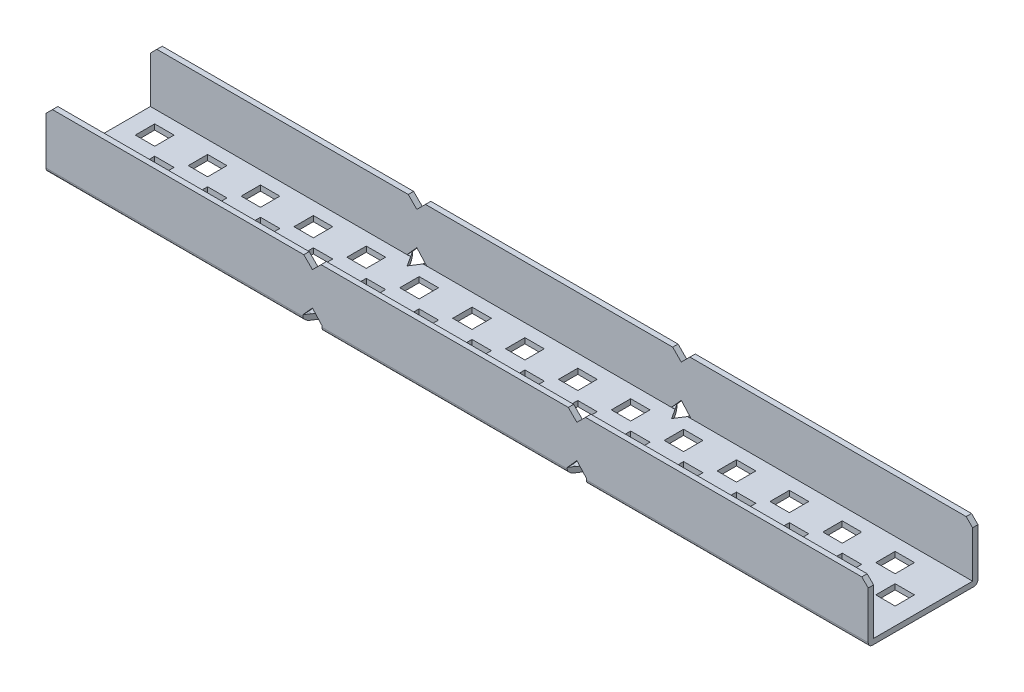
from build123d import *

# Parameters (mm, degrees)
SKETCH1_W           = 191
SKETCH1_H           = 25.5
BOSS_EXTRUDE1_DEPTH = 1.25
SKETCH2_W           = 191
SKETCH2_H           = 1.25
BOSS_EXTRUDE2_DEPTH = 12.25
SKETCH3_W           = 4.5
SKETCH3_H           = 4.5
CUT_EXTRUDE1_DEPTH  = 12.25
CUT_EXTRUDE2_DEPTH  = 1.3
CUT_EXTRUDE4_DEPTH  = 48.3
CUT_EXTRUDE5_DEPTH  = 48.3
FILLET1_R           = 1


with BuildPart() as part:
    # Sketch1 → Boss-Extrude1 (new body)
    with BuildSketch(Plane(origin=(0, 0, 0), x_dir=(1, 0, 0), z_dir=(0, 1, 0))):
        with Locations((95.5, 12.75)):
            Rectangle(SKETCH1_W, SKETCH1_H)
    extrude(amount=BOSS_EXTRUDE1_DEPTH)

    # Sketch2 → Boss-Extrude2 (add)
    with BuildSketch(Plane(origin=(0, 1.25, 0), x_dir=(1, 0, 0), z_dir=(0, 1, 0))):
        with Locations((95.5, 24.875)):
            Rectangle(SKETCH2_W, SKETCH2_H)
        with Locations((95.5, 0.625)):
            Rectangle(SKETCH2_W, SKETCH2_H)
    extrude(amount=BOSS_EXTRUDE2_DEPTH)

    # Sketch3 → Cut-Extrude1 (cut)
    with BuildSketch(Plane(origin=(0, 0, 0), x_dir=(-1, 0, 0), z_dir=(0, -1, 0))):
        with Locations((-6.25, 6.5)):
            Rectangle(SKETCH3_W, SKETCH3_H)
        with Locations((-6.25, 19)):
            Rectangle(SKETCH3_W, SKETCH3_H)
        with Locations((-18.535714286, 6.5)):
            Rectangle(SKETCH3_W, SKETCH3_H)
        with Locations((-12.75, 12.5)):
            Rectangle(SKETCH3_W, SKETCH3_H)
        with Locations((-18.535714286, 19)):
            Rectangle(SKETCH3_W, SKETCH3_H)
        with Locations((-25.035714286, 12.5)):
            Rectangle(SKETCH3_W, SKETCH3_H)
        with Locations((-30.821428571, 6.5)):
            Rectangle(SKETCH3_W, SKETCH3_H)
        with Locations((-30.821428571, 19)):
            Rectangle(SKETCH3_W, SKETCH3_H)
        with Locations((-37.321428571, 12.5)):
            Rectangle(SKETCH3_W, SKETCH3_H)
        with Locations((-43.107142857, 6.5)):
            Rectangle(SKETCH3_W, SKETCH3_H)
        with Locations((-43.107142857, 19)):
            Rectangle(SKETCH3_W, SKETCH3_H)
        with Locations((-49.607142857, 12.5)):
            Rectangle(SKETCH3_W, SKETCH3_H)
        with Locations((-55.392857143, 6.5)):
            Rectangle(SKETCH3_W, SKETCH3_H)
        with Locations((-55.392857143, 19)):
            Rectangle(SKETCH3_W, SKETCH3_H)
        with Locations((-61.892857143, 12.5)):
            Rectangle(SKETCH3_W, SKETCH3_H)
        with Locations((-67.678571429, 6.5)):
            Rectangle(SKETCH3_W, SKETCH3_H)
        with Locations((-67.678571429, 19)):
            Rectangle(SKETCH3_W, SKETCH3_H)
        with Locations((-74.178571429, 12.5)):
            Rectangle(SKETCH3_W, SKETCH3_H)
        with Locations((-79.964285714, 6.5)):
            Rectangle(SKETCH3_W, SKETCH3_H)
        with Locations((-79.964285714, 19)):
            Rectangle(SKETCH3_W, SKETCH3_H)
        with Locations((-86.464285714, 12.5)):
            Rectangle(SKETCH3_W, SKETCH3_H)
        with Locations((-92.25, 6.5)):
            Rectangle(SKETCH3_W, SKETCH3_H)
        with Locations((-92.25, 19)):
            Rectangle(SKETCH3_W, SKETCH3_H)
        with Locations((-98.75, 12.5)):
            Rectangle(SKETCH3_W, SKETCH3_H)
        with Locations((-104.535714286, 6.5)):
            Rectangle(SKETCH3_W, SKETCH3_H)
        with Locations((-104.535714286, 19)):
            Rectangle(SKETCH3_W, SKETCH3_H)
        with Locations((-111.035714286, 12.5)):
            Rectangle(SKETCH3_W, SKETCH3_H)
        with Locations((-116.821428571, 6.5)):
            Rectangle(SKETCH3_W, SKETCH3_H)
        with Locations((-116.821428571, 19)):
            Rectangle(SKETCH3_W, SKETCH3_H)
        with Locations((-123.321428571, 12.5)):
            Rectangle(SKETCH3_W, SKETCH3_H)
        with Locations((-129.107142857, 6.5)):
            Rectangle(SKETCH3_W, SKETCH3_H)
        with Locations((-129.107142857, 19)):
            Rectangle(SKETCH3_W, SKETCH3_H)
        with Locations((-135.607142857, 12.5)):
            Rectangle(SKETCH3_W, SKETCH3_H)
        with Locations((-141.392857143, 6.5)):
            Rectangle(SKETCH3_W, SKETCH3_H)
        with Locations((-141.392857143, 19)):
            Rectangle(SKETCH3_W, SKETCH3_H)
        with Locations((-147.892857143, 12.5)):
            Rectangle(SKETCH3_W, SKETCH3_H)
        with Locations((-153.678571429, 6.5)):
            Rectangle(SKETCH3_W, SKETCH3_H)
        with Locations((-153.678571429, 19)):
            Rectangle(SKETCH3_W, SKETCH3_H)
        with Locations((-160.178571429, 12.5)):
            Rectangle(SKETCH3_W, SKETCH3_H)
        with Locations((-165.964285714, 6.5)):
            Rectangle(SKETCH3_W, SKETCH3_H)
        with Locations((-165.964285714, 19)):
            Rectangle(SKETCH3_W, SKETCH3_H)
        with Locations((-172.464285714, 12.5)):
            Rectangle(SKETCH3_W, SKETCH3_H)
        with Locations((-178.25, 6.5)):
            Rectangle(SKETCH3_W, SKETCH3_H)
        with Locations((-178.25, 19)):
            Rectangle(SKETCH3_W, SKETCH3_H)
        with Locations((-184.75, 12.5)):
            Rectangle(SKETCH3_W, SKETCH3_H)
    extrude(amount=-CUT_EXTRUDE1_DEPTH, mode=Mode.SUBTRACT)

    # Sketch4 → Cut-Extrude2 (cut)
    with BuildSketch(Plane.XZ):
        Polygon((61.892857143, -3.5), (59.642857143, 0), (64.142857143, 0), align=None)
        Polygon((123.321428571, -3.5), (121.071428571, 0), (125.571428571, 0), align=None)
        Polygon((121.071428571, -25.5), (125.571428571, -25.5), (123.321428571, -22), align=None)
        Polygon((59.642857143, -25.5), (64.142857143, -25.5), (61.892857143, -22), align=None)
    extrude(amount=-CUT_EXTRUDE2_DEPTH, mode=Mode.SUBTRACT)

    # Sketch6 → Cut-Extrude4 (cut)
    with BuildSketch(Plane(origin=(0, 0, -25.5), x_dir=(-1, 0, 0), z_dir=(0, 0, -1))):
        Polygon((-123.321428571, 3.8), (-121.071428571, 1.3), (-125.571428571, 1.3), align=None)
        Polygon((-61.892857143, 3.8), (-59.642857143, 1.3), (-64.142857143, 1.3), align=None)
        Polygon((-125.321428571, 13.5), (-121.321428571, 13.5), (-123.321428571, 11.5), align=None)
        Polygon((-63.892857143, 13.5), (-59.892857143, 13.5), (-61.892857143, 11.5), align=None)
    extrude(amount=-CUT_EXTRUDE4_DEPTH, mode=Mode.SUBTRACT)

    # Sketch7 → Cut-Extrude5 (cut)
    with BuildSketch(Plane(origin=(0, 0, -25.5), x_dir=(-1, 0, 0), z_dir=(0, 0, -1))):
        Polygon((-191, 13.5), (-191, 12), (-189.5, 13.5), align=None)
        Polygon((-1.5, 13.5), (0, 13.5), (0, 12), align=None)
    extrude(amount=-CUT_EXTRUDE5_DEPTH, mode=Mode.SUBTRACT)

    # Fillet1
    fillet1_edges = [part.edges().sort_by_distance(p)[0] for p in [
        (158.285714286, 0, -25.5),
        (29.821428571, 0, 0),
        (92.607142857, 0, 0),
        (92.607142857, 0, -25.5),
        (29.821428571, 0, -25.5),
        (158.285714286, 0, 0),
    ]]
    fillet(fillet1_edges, radius=FILLET1_R)


solid = part.part
